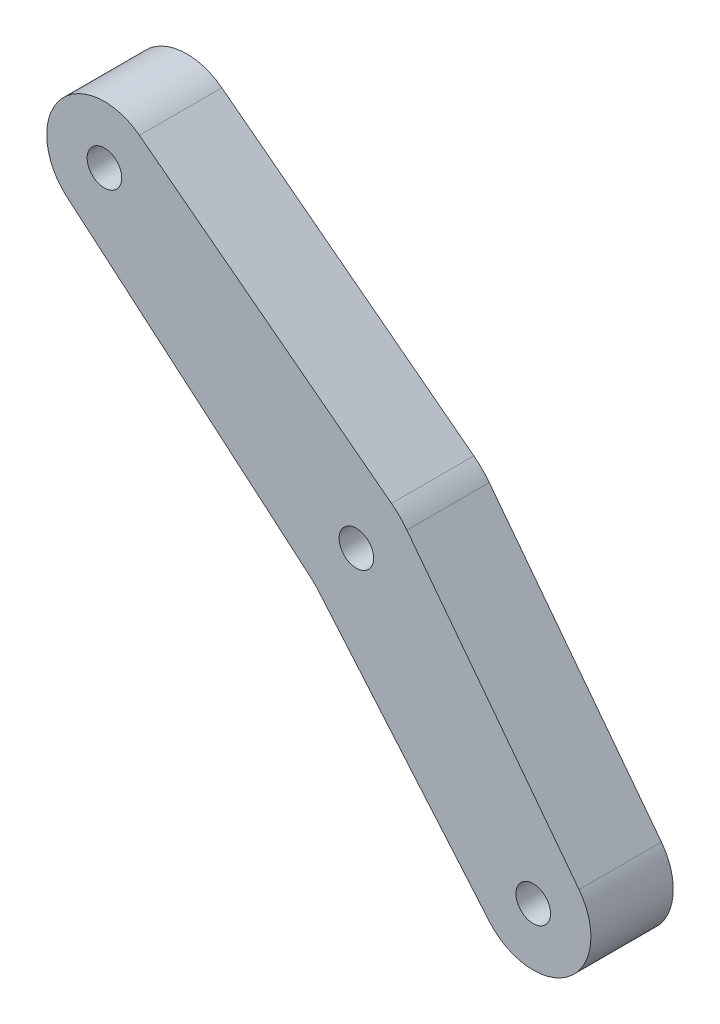
from build123d import *

# Parameters (mm, degrees)
CROQUIS1_R              = 2.1
SALIENTE_EXTRUIR1_DEPTH = 10


with BuildPart() as part:
    # Croquis1 → Saliente-Extruir1 (new body)
    with BuildSketch(Plane.XY):
        with BuildLine():
            Line((-58.801310312, 52.400771547), (-28.208421346, 29.003542717))
            ThreePointArc((-28.208421346, 29.003542717), (-27.21125434, 28.130328998), (-26.338333202, 27.132905856))
            Line((-26.338333202, 27.132905856), (-5.438481723, -0.21117485))
            ThreePointArc((-5.438481723, -0.21117485), (-6.605047925, -9.910338853), (-16.33142541, -8.998066919))
            Line((-16.33142541, -8.998066919), (-37.011618384, 15.308211684))
            ThreePointArc((-37.011618384, 15.308211684), (-37.555835427, 15.898146585), (-38.145610643, 16.442536676))
            Line((-38.145610643, 16.442536676), (-67.591397717, 41.51040618))
            ThreePointArc((-67.591397717, 41.51040618), (-68.500816139, 51.237050884), (-58.801310312, 52.400771547))
        make_face()
        with Locations((-63.053766888, 46.840500594)):
            Circle(CROQUIS1_R, mode=Mode.SUBTRACT)
        with Locations((-32.472451023, 22.156990874)):
            Circle(CROQUIS1_R, mode=Mode.SUBTRACT)
        with Locations((-11, -4.462)):
            Circle(CROQUIS1_R, mode=Mode.SUBTRACT)
    extrude(amount=SALIENTE_EXTRUIR1_DEPTH)


solid = part.part
